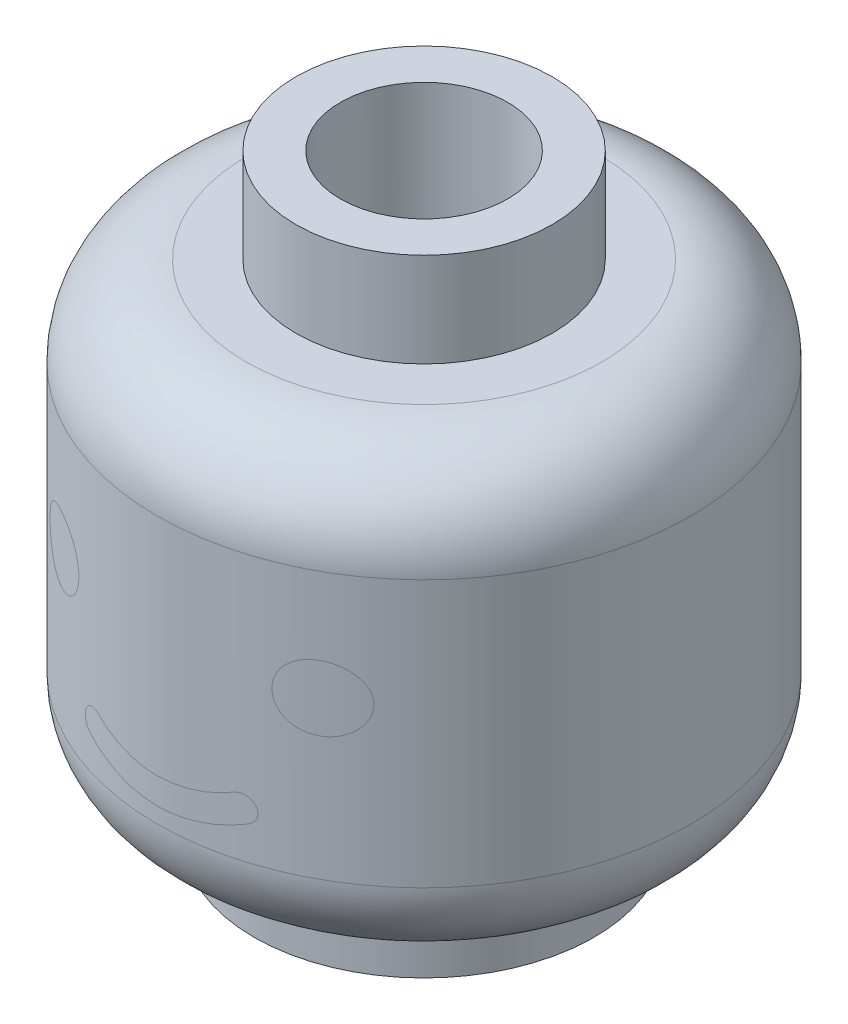
from build123d import *

# Parameters (mm, degrees)
AIR_HOLE_DEPTH    = 10
CIRCPATTERN_COUNT = 3


with BuildPart() as part:
    # Sketch1 → Head Revolve (revolve)
    with BuildSketch(Plane(origin=(0, 0, 0), x_dir=(0, 0, -1), z_dir=(1, 0, 0))):
        with BuildLine():
            Line((0, 8.5), (0, 9.4))
            Line((0, 9.4), (1.6, 9.4))
            Line((1.6, 9.4), (1.6, 11.4))
            Line((1.6, 11.4), (2.45, 11.4))
            Line((2.45, 11.4), (2.45, 9.6))
            Line((2.45, 9.6), (3.4, 9.6))
            ThreePointArc((3.4, 9.6), (4.602081528, 9.102081528), (5.1, 7.9))
            Line((5.1, 7.9), (5.1, 2.8))
            ThreePointArc((5.1, 2.8), (4.602081528, 1.597918472), (3.4, 1.1))
            Line((3.4, 1.1), (3.25, 1.1))
            Line((3.25, 1.1), (3.25, 0))
            Line((3.25, 0), (2.45, 0))
            Line((2.45, 0), (2.45, 8.5))
            Line((2.45, 8.5), (0, 8.5))
        make_face()
    revolve(axis=Axis((0, 16.31372549, 0), (0, -1, 0)))

    # Sketch2 → Air Hole (cut)
    with BuildSketch(Plane(origin=(0, 9.4, 0), x_dir=(1, 0, 0), z_dir=(0, 1, 0))):
        with BuildLine():
            Line((-0.42, 1.543891188), (-0.42, 0.242487113))
            Line((-0.42, 0.242487113), (-1.547048989, -0.408214924))
            ThreePointArc((-1.547048989, -0.408214924), (-1.385640646, 0.8), (-0.42, 1.543891188))
        make_face()
    air_hole = extrude(amount=-AIR_HOLE_DEPTH, mode=Mode.SUBTRACT)

    # CircPattern: Air Hole ×3 about axis
    circpattern_axis = Axis((0, 0, 0), (0, 1, 0))
    for i in range(1, CIRCPATTERN_COUNT):
        add(air_hole.rotate(circpattern_axis, i * 360 / CIRCPATTERN_COUNT), mode=Mode.SUBTRACT)


solid = part.part
